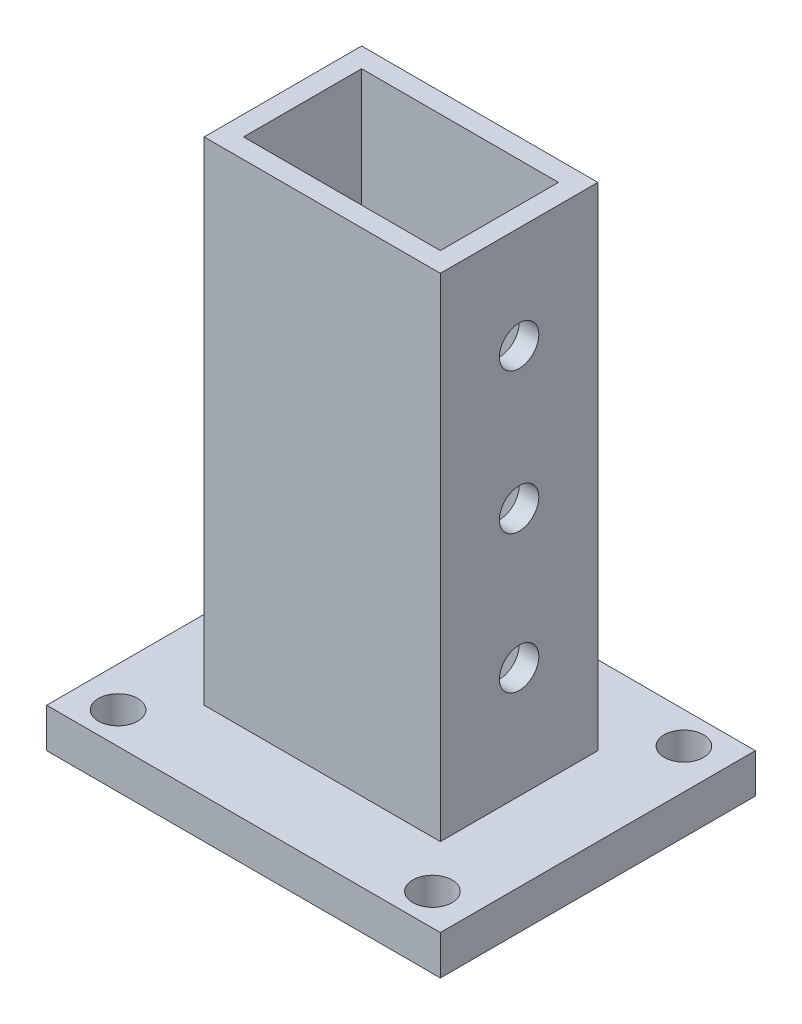
from build123d import *

# Parameters (mm, degrees)
SZKIC1_W                          = 100
SZKIC1_H                          = 80
SZKIC1_R                          = 5
DODANIE_WYCI_GNI_CIE1_DEPTH       = 10
SZKIC2_W                          = 60
SZKIC2_H                          = 40
SZKIC2_W_2                        = 50
SZKIC2_H_2                        = 30
WYCI_GNI_CIE_CIENKA_CIANKA1_DEPTH = 125
SZKIC3_R                          = 5
WYTNIJ_WYCI_GNI_CIE1_DEPTH        = 125


with BuildPart() as part:
    # Szkic1 → Dodanie-wyciągnięcie1 (new body)
    with BuildSketch(Plane(origin=(0, 0, 0), x_dir=(1, 0, 0), z_dir=(0, 1, 0))):
        Rectangle(SZKIC1_W, SZKIC1_H)
        with Locations((-39.918726622, 31.934981298)):
            Circle(SZKIC1_R, mode=Mode.SUBTRACT)
        with Locations((39.918726622, 31.934981298)):
            Circle(SZKIC1_R, mode=Mode.SUBTRACT)
        with Locations((39.918726622, -31.934981298)):
            Circle(SZKIC1_R, mode=Mode.SUBTRACT)
        with Locations((-39.918726622, -31.934981298)):
            Circle(SZKIC1_R, mode=Mode.SUBTRACT)
    extrude(amount=DODANIE_WYCI_GNI_CIE1_DEPTH)

    # Szkic2 → Wyciągnięcie-cienka ścianka1 (add)
    with BuildSketch(Plane(origin=(0, 10, 0), x_dir=(1, 0, 0), z_dir=(0, 1, 0))):
        Rectangle(SZKIC2_W, SZKIC2_H)
        Rectangle(SZKIC2_W_2, SZKIC2_H_2, mode=Mode.SUBTRACT)
    extrude(amount=WYCI_GNI_CIE_CIENKA_CIANKA1_DEPTH)

    # Szkic3 → Wytnij-wyciągnięcie1 (cut)
    with BuildSketch(Plane.ZY.offset(30)):
        with Locations((0, 38.229088524)):
            Circle(SZKIC3_R)
        with Locations((0, 73.280775621)):
            Circle(SZKIC3_R)
        with Locations((0, 109.066529463)):
            Circle(SZKIC3_R)
    extrude(amount=-WYTNIJ_WYCI_GNI_CIE1_DEPTH, mode=Mode.SUBTRACT)


solid = part.part
